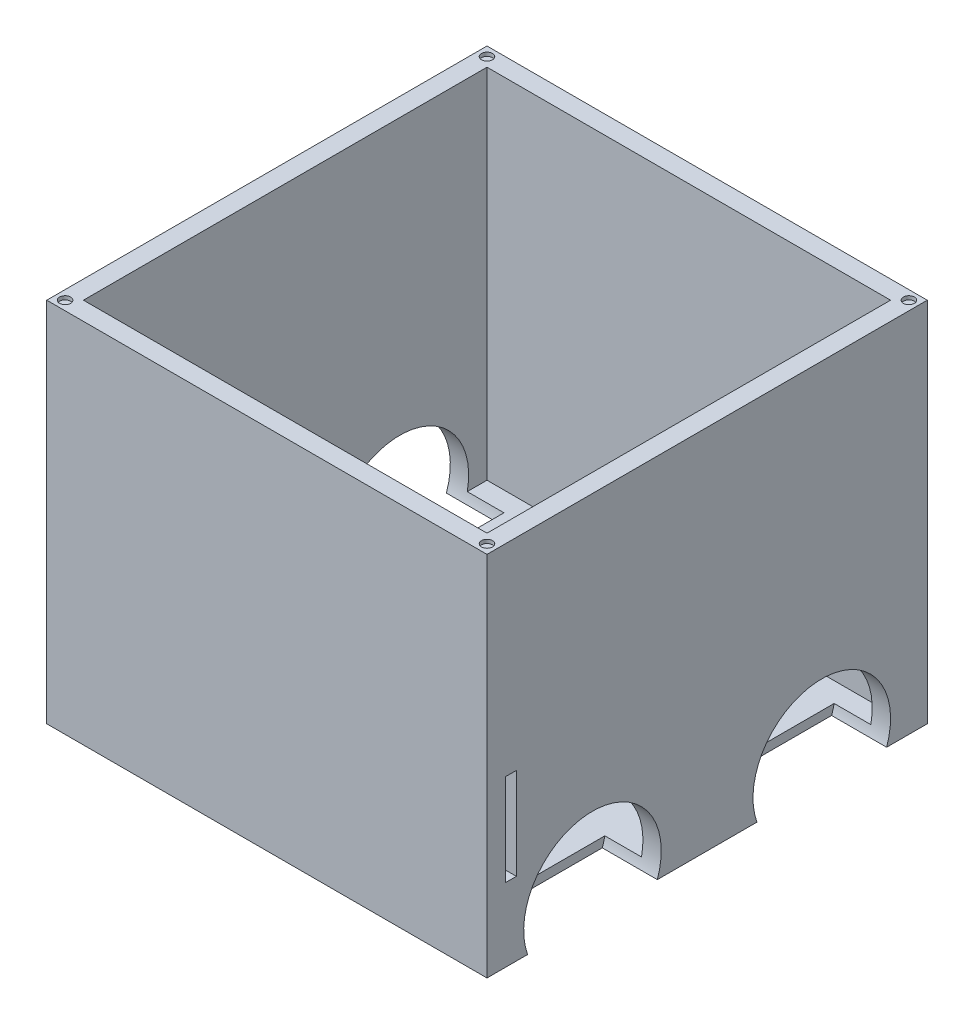
from build123d import *

# Parameters (mm, degrees)
SKETCH2_W               = 240
SKETCH2_H               = 240
BOSS_EXTRUDE1_DEPTH     = 200
SKETCH17_W              = 220
SKETCH17_H              = 220
CUT_EXTRUDE1_DEPTH      = 195
SKETCH20_R              = 37.5
CUT_EXTRUDE3_DEPTH      = 30
SKETCH21_R              = 37.5
CUT_EXTRUDE4_DEPTH      = 30
SKETCH22_R              = 3
CUT_EXTRUDE5_DEPTH      = 2
SKETCH24_W              = 6
SKETCH24_H              = 50
CUT_EXTRUDE7_DEPTH      = 1
CUT_EXTRUDE7_DEPTH_BACK = 241


with BuildPart() as part:
    # Sketch2 → Boss-Extrude1 (new body)
    with BuildSketch(Plane(origin=(0, -113.102021597, 0), x_dir=(1, 0, 0), z_dir=(0, 1, 0))):
        Rectangle(SKETCH2_W, SKETCH2_H)
    extrude(amount=BOSS_EXTRUDE1_DEPTH)

    # Sketch17 → Cut-Extrude1 (cut)
    with BuildSketch(Plane(origin=(0, 86.897978403, 0), x_dir=(1, 0, 0), z_dir=(0, 1, 0))):
        Rectangle(SKETCH17_W, SKETCH17_H)
    extrude(amount=-CUT_EXTRUDE1_DEPTH, mode=Mode.SUBTRACT)

    # Sketch20 → Cut-Extrude3 (cut)
    with BuildSketch(Plane(origin=(120, 0, 0), x_dir=(0, 0, -1), z_dir=(1, 0, 0))):
        with Locations((-62.5, -100.602021597)):
            Circle(SKETCH20_R)
        with Locations((62.5, -100.602021597)):
            Circle(SKETCH20_R)
    extrude(amount=-CUT_EXTRUDE3_DEPTH, mode=Mode.SUBTRACT)

    # Sketch21 → Cut-Extrude4 (cut)
    with BuildSketch(Plane.ZY.offset(120)):
        with Locations((62.5, -100.602021597)):
            Circle(SKETCH21_R)
        with Locations((-62.5, -100.602021597)):
            Circle(SKETCH21_R)
    extrude(amount=-CUT_EXTRUDE4_DEPTH, mode=Mode.SUBTRACT)

    # Sketch22 → Cut-Extrude5 (cut)
    with BuildSketch(Plane(origin=(0, 86.897978403, 0), x_dir=(1, 0, 0), z_dir=(0, 1, 0))):
        with Locations((-115, 115)):
            Circle(SKETCH22_R)
        with Locations((-115, -115)):
            Circle(SKETCH22_R)
        with Locations((115, -115)):
            Circle(SKETCH22_R)
        with Locations((115, 115)):
            Circle(SKETCH22_R)
    extrude(amount=-CUT_EXTRUDE5_DEPTH, mode=Mode.SUBTRACT)

    # Sketch24 → Cut-Extrude7 (cut, two sides)
    with BuildSketch(Plane.ZY.offset(120)) as cut_extrude7_sk:
        with Locations((107, -48.102021597)):
            Rectangle(SKETCH24_W, SKETCH24_H)
    extrude(amount=CUT_EXTRUDE7_DEPTH, mode=Mode.SUBTRACT)
    extrude(cut_extrude7_sk.sketch, amount=-CUT_EXTRUDE7_DEPTH_BACK, mode=Mode.SUBTRACT)


solid = part.part
